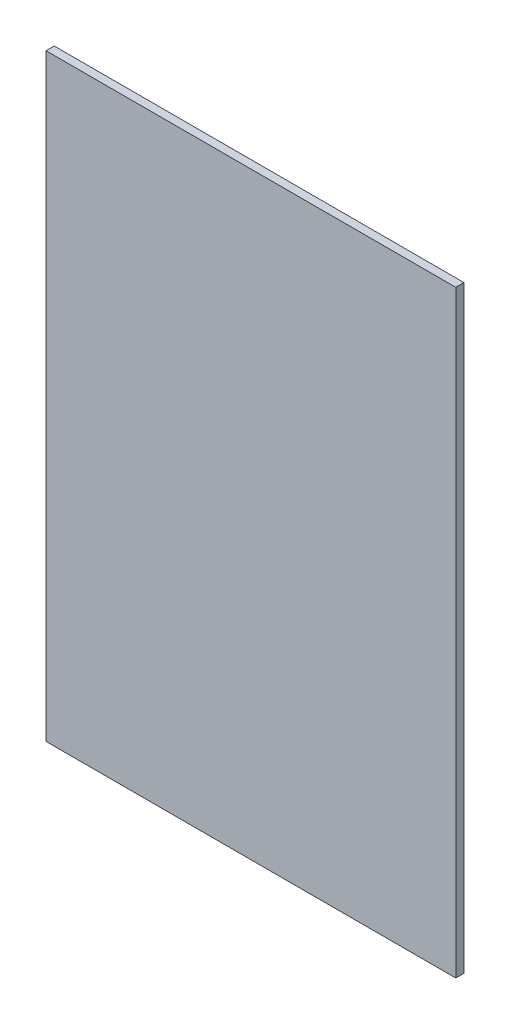
from build123d import *

# Parameters (mm, degrees)
SKETCH1_W           = 317.5
SKETCH1_H           = 463.55
BOSS_EXTRUDE1_DEPTH = 6.35


with BuildPart() as part:
    # Sketch1 → Boss-Extrude1 (new body)
    with BuildSketch(Plane.XY):
        with Locations((158.75, 231.775)):
            Rectangle(SKETCH1_W, SKETCH1_H)
    extrude(amount=BOSS_EXTRUDE1_DEPTH)


solid = part.part
